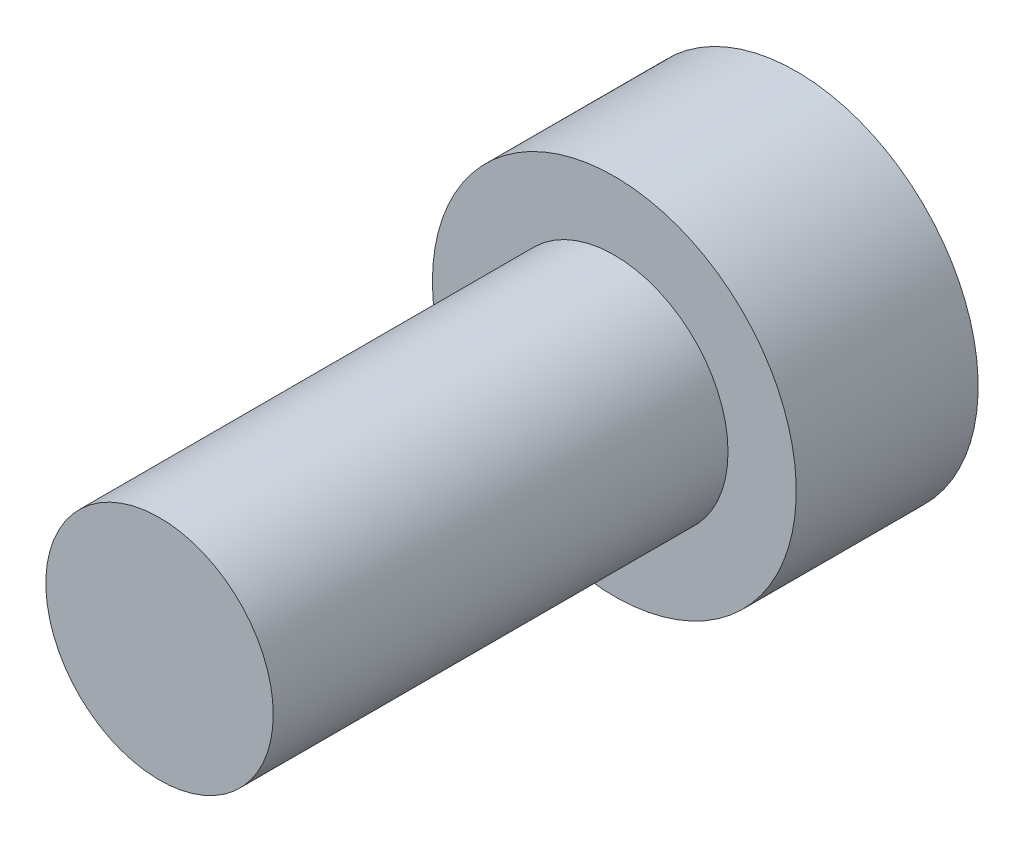
from build123d import *

# Parameters (mm, degrees)
SKETCH1_R           = 2.5
BOSS_EXTRUDE1_DEPTH = 10
SKETCH2_R           = 4
BOSS_EXTRUDE2_DEPTH = 4
CUT_EXTRUDE1_DEPTH  = 3


with BuildPart() as part:
    # Sketch1 → Boss-Extrude1 (new body)
    with BuildSketch(Plane.XY):
        Circle(SKETCH1_R)
    extrude(amount=BOSS_EXTRUDE1_DEPTH)

    # Sketch2 → Boss-Extrude2 (add)
    with BuildSketch(Plane(origin=(0, 0, 0), x_dir=(-1, 0, 0), z_dir=(0, 0, -1))):
        Circle(SKETCH2_R)
    extrude(amount=BOSS_EXTRUDE2_DEPTH)

    # Sketch3 → Cut-Extrude1 (cut)
    with BuildSketch(Plane(origin=(0, 0, -4), x_dir=(-1, 0, 0), z_dir=(0, 0, -1))):
        Polygon((1.732050808, -3), (3.464101615, 0), (1.732050808, 3), (-1.732050808, 3), (-3.464101615, 0), (-1.732050808, -3), align=None)
    extrude(amount=-CUT_EXTRUDE1_DEPTH, mode=Mode.SUBTRACT)


solid = part.part
